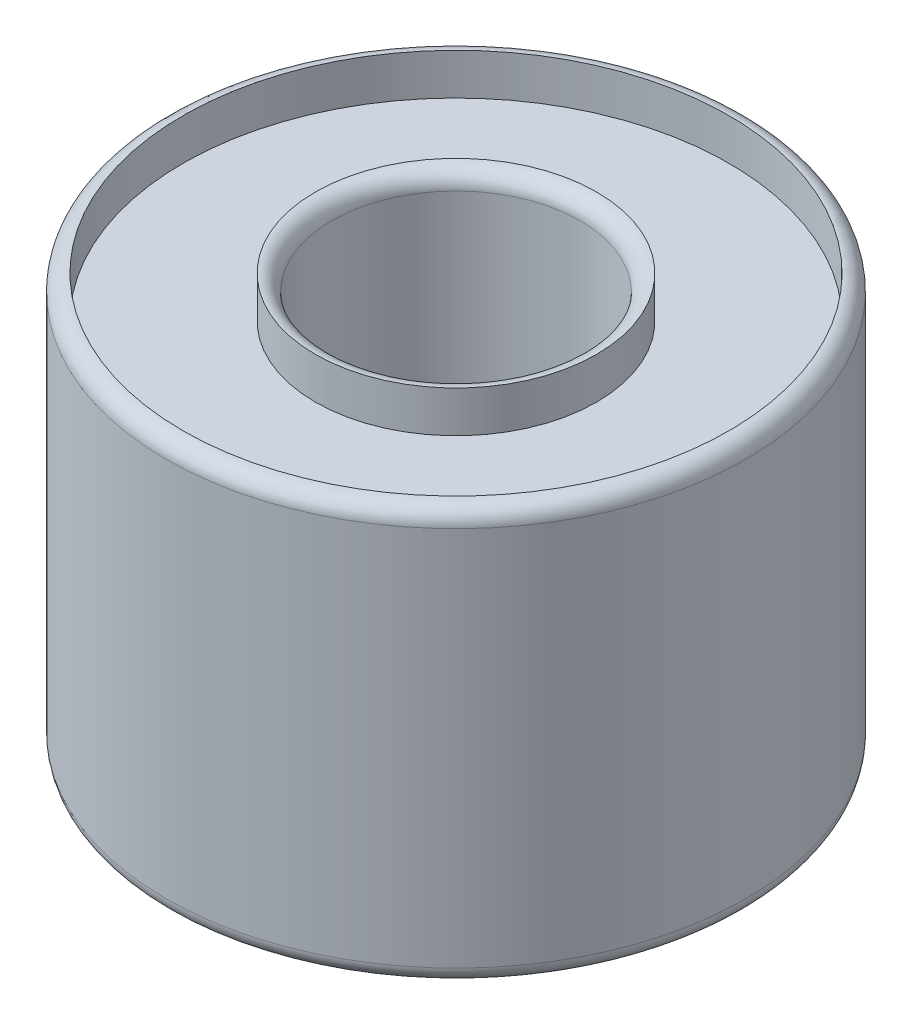
from build123d import *

# Parameters (mm, degrees)
ESQUISSE1_R             = 3.5
ESQUISSE1_R_2           = 1.5
BOSS_EXTRU_1_DEPTH      = 5
CONG_1_R                = 0.2
ESQUISSE3_R             = 3.3
ESQUISSE3_R_2           = 1.7
ENL_V_MAT_EXTRU_1_DEPTH = 0.5
ESQUISSE4_R             = 3.3
ESQUISSE4_R_2           = 1.7
ENL_V_MAT_EXTRU_2_DEPTH = 0.5


with BuildPart() as part:
    # Esquisse1 → Boss.-Extru.1 (new body)
    with BuildSketch(Plane(origin=(0, 0, 0), x_dir=(1, 0, 0), z_dir=(0, 1, 0))):
        Circle(ESQUISSE1_R)
        Circle(ESQUISSE1_R_2, mode=Mode.SUBTRACT)
    extrude(amount=BOSS_EXTRU_1_DEPTH)

    # Congé1
    cong_1_edges = [part.edges().sort_by_distance(p)[0] for p in [
        (-3.5, 0, 0),
        (-3.5, 5, 0),
        (-1.5, 0, 0),
        (-1.5, 5, 0),
    ]]
    fillet(cong_1_edges, radius=CONG_1_R)

    # Esquisse3 → Enlèv. mat.-Extru.1 (cut)
    with BuildSketch(Plane(origin=(0, 5, 0), x_dir=(1, 0, 0), z_dir=(0, 1, 0))):
        Circle(ESQUISSE3_R)
        Circle(ESQUISSE3_R_2, mode=Mode.SUBTRACT)
    extrude(amount=-ENL_V_MAT_EXTRU_1_DEPTH, mode=Mode.SUBTRACT)

    # Esquisse4 → Enlèv. mat.-Extru.2 (cut)
    with BuildSketch(Plane.XZ):
        Circle(ESQUISSE4_R)
        Circle(ESQUISSE4_R_2, mode=Mode.SUBTRACT)
    extrude(amount=-ENL_V_MAT_EXTRU_2_DEPTH, mode=Mode.SUBTRACT)


solid = part.part
